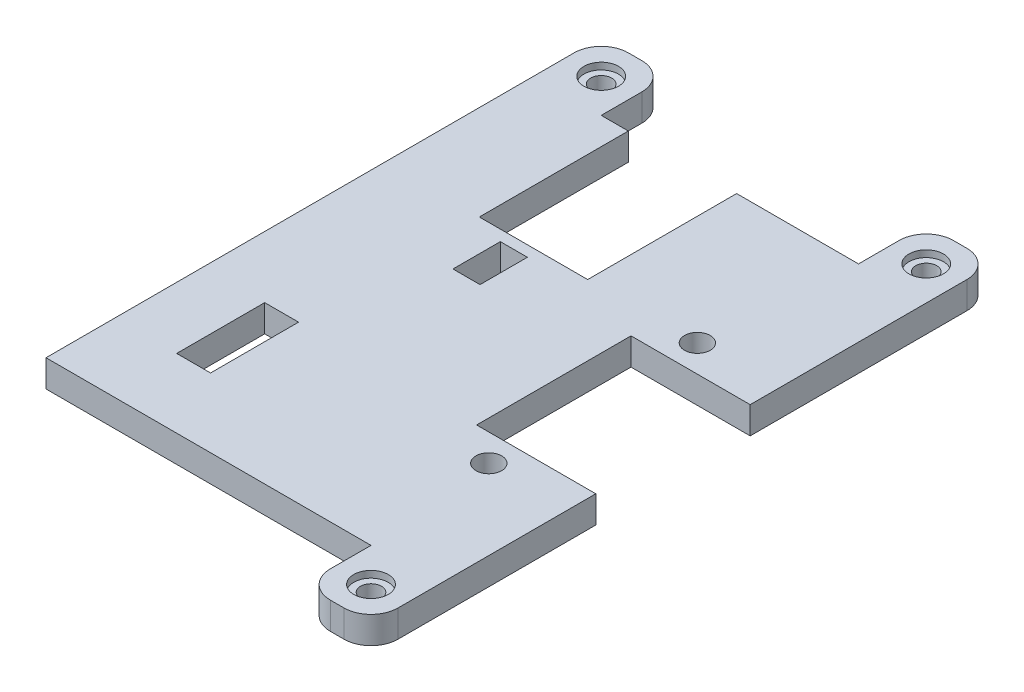
from build123d import *

# Parameters (mm, degrees)
SKETCH1_R           = 0.775
BOSS_EXTRUDE1_DEPTH = 2
SKETCH2_R           = 0.95
SKETCH2_W           = 8
SKETCH2_H           = 11
SKETCH2_W_2         = 8.8
SKETCH2_H_2         = 11.4
SKETCH2_W_3         = 2
SKETCH2_H_3         = 3.5
SKETCH2_W_4         = 2.5
SKETCH2_H_4         = 6.5
CUT_EXTRUDE1_DEPTH  = 3
FILLET1_R           = 2
SKETCH3_R           = 1.275
CUT_EXTRUDE2_DEPTH  = 0.5


with BuildPart() as part:
    # Sketch1 → Boss-Extrude1 (new body)
    with BuildSketch(Plane(origin=(0, 0, 0), x_dir=(1, 0, 0), z_dir=(0, 1, 0))):
        Polygon((18.486983138, -44.730983302), (23.486983138, -44.730983302), (23.486983138, 1.269016698), (18.486983138, 1.269016698), (18.486983138, -3.730983302), (-0.513016862, -3.730983302), (-0.513016862, 1.269016698), (-5.513016862, 1.269016698), (-5.513016862, -39.730983302), (-0.513016862, -39.730983302), (18.486983138, -39.730983302), align=None)
        with Locations((-3.013016862, -1.230983302)):
            Circle(SKETCH1_R, mode=Mode.SUBTRACT)
        with Locations((20.986983138, -1.230983302)):
            Circle(SKETCH1_R, mode=Mode.SUBTRACT)
        with Locations((20.986983138, -42.230983302)):
            Circle(SKETCH1_R, mode=Mode.SUBTRACT)
    extrude(amount=BOSS_EXTRUDE1_DEPTH)

    # Sketch2 → Cut-Extrude1 (cut, through all)
    with BuildSketch(Plane(origin=(0, 2, 0), x_dir=(1, 0, 0), z_dir=(0, 1, 0))):
        with Locations((17.586983138, -14.730983302)):
            Circle(SKETCH2_R)
        with Locations((17.586983138, -30.130983302)):
            Circle(SKETCH2_R)
        with Locations((5.486983138, -9.230983302)):
            Rectangle(SKETCH2_W, SKETCH2_H)
        with Locations((19.086983138, -22.430983302)):
            Rectangle(SKETCH2_W_2, SKETCH2_H_2)
        with Locations((4.836983138, -17.280983302)):
            Rectangle(SKETCH2_W_3, SKETCH2_H_3)
        with Locations((0.286983138, -31.380983302)):
            Rectangle(SKETCH2_W_4, SKETCH2_H_4)
    extrude(amount=-CUT_EXTRUDE1_DEPTH, mode=Mode.SUBTRACT)

    # Fillet1
    fillet1_edges = [part.edges().sort_by_distance(p)[0] for p in [
        (-5.513016862, 1, -1.269016698),
        (-0.513016862, 1, -1.269016698),
        (18.486983138, 1, -1.269016698),
        (23.486983138, 1, -1.269016698),
        (23.486983138, 1, 44.730983302),
        (18.486983138, 1, 44.730983302),
    ]]
    fillet(fillet1_edges, radius=FILLET1_R)

    # Sketch3 → Cut-Extrude2 (cut)
    with BuildSketch(Plane(origin=(0, 2, 0), x_dir=(1, 0, 0), z_dir=(0, 1, 0))):
        with Locations((-3.013016862, -1.230983302)):
            Circle(SKETCH3_R)
        with Locations((20.986983138, -1.230983302)):
            Circle(SKETCH3_R)
        with Locations((20.986983138, -42.230983302)):
            Circle(SKETCH3_R)
    extrude(amount=-CUT_EXTRUDE2_DEPTH, mode=Mode.SUBTRACT)


solid = part.part
